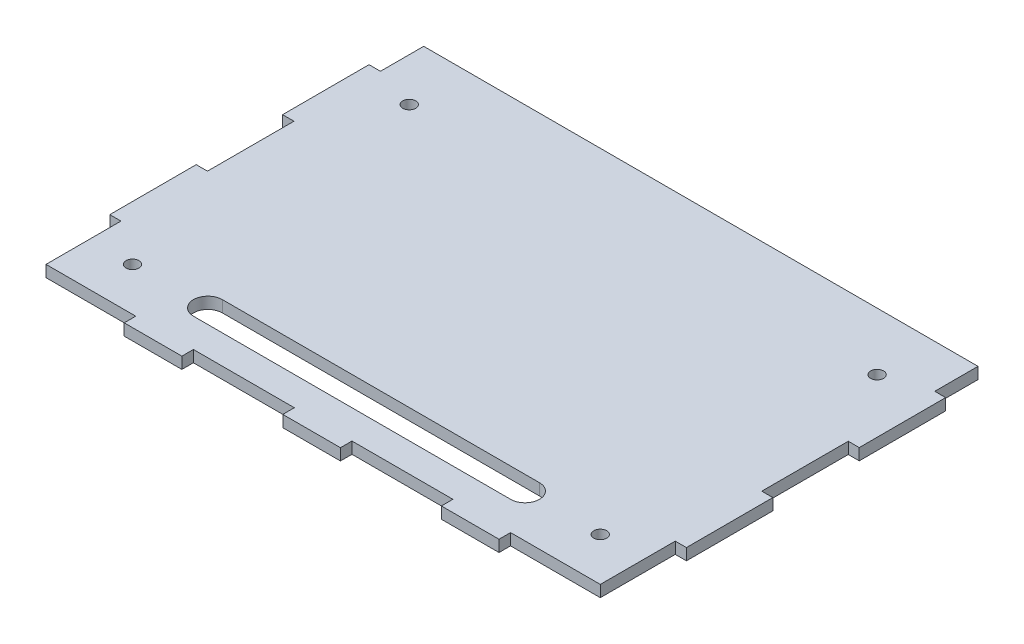
from build123d import *

# Parameters (mm, degrees)
RESSALTO_EXTRUS_O1_DEPTH = 4
ESBO_O2_W                = 35
ESBO_O2_H                = 4
ESBO_O2_W_2              = 3.874378487
ESBO_O2_H_2              = 26.000016438
CORTE_EXTRUS_O1_DEPTH    = 5
CORTE_EXTRUS_O5_REACH    = 6
ESBO_O6_W                = 32.376232368
ESBO_O6_H                = 43.313616366
ESBO_O3_W                = 192.251243026
ESBO_O3_H                = 15
CORTE_EXTRUS_O3_DEPTH    = 5
FURO_COM_FOLGA_DE_M41_D  = 4.5
ESBO_O5_R                = 2.25
CORTE_EXTRUS_O4_DEPTH    = 5


with BuildPart() as part:
    # Esboço1 → Ressalto-extrusão1 (new body)
    with BuildSketch(Plane(origin=(0, 0, 0), x_dir=(1, 0, 0), z_dir=(0, 1, 0))):
        Polygon((-100.157081707, 150), (-100.000054794, 0), (100.000054794, 0), (99.843027881, 150), align=None)
    extrude(amount=RESSALTO_EXTRUS_O1_DEPTH)

    # Esboço2 → Corte-extrusão1 (cut, through all)
    with BuildSketch(Plane(origin=(0, 4, 0), x_dir=(1, 0, 0), z_dir=(0, 1, 0))):
        Polygon((-100.125676325, 120), (-96.157081707, 120), (-96.157081707, 150), (-100.157081707, 150), align=None)
        Polygon((-100.062865577, 60.000016438), (-96.157081707, 60.000016438), (-96.157081707, 90), (-100.094270942, 90), align=None)
        Polygon((-100.004242179, 4), (-96.157081707, 4), (-96.157081707, 30.000016438), (-100.031460194, 30.000016438), align=None)
        Polygon((-100.000054794, 0), (-65.031460194, 0), (-65.031460194, 4), (-96.157081707, 4), (-100.004242179, 4), align=None)
        with Locations((-27.531460194, 2)):
            Rectangle(ESBO_O2_W, ESBO_O2_H)
        with Locations((27.468539806, 2)):
            Rectangle(ESBO_O2_W, ESBO_O2_H)
        Polygon((64.968539806, 4), (64.968539806, 0), (99.968539806, 0), (99.968539806, 4), (96.094161319, 4), align=None)
        with Locations((98.031350563, 17.000008219)):
            Rectangle(ESBO_O2_W_2, ESBO_O2_H_2)
        Polygon((96.094161319, 60.000016438), (99.937244012, 60.000016438), (99.905838646, 90), (96.094161319, 90), align=None)
        Polygon((99.843027881, 150), (96.094161319, 150), (96.094161319, 120), (99.874433264, 120), align=None)
    extrude(amount=-CORTE_EXTRUS_O1_DEPTH, mode=Mode.SUBTRACT)

    # Esboço6 → Corte-extrusão5 (cut, up to next)
    with BuildSketch(Plane(origin=(0, 4, 0), x_dir=(1, 0, 0), z_dir=(0, 1, 0)), mode=Mode.PRIVATE) as corte_extrus_o5_sk1:
        with Locations((112.282277503, 8.343208255)):
            Rectangle(ESBO_O6_W, ESBO_O6_H)
    corte_extrus_o5_tool1 = extrude(corte_extrus_o5_sk1.sketch, amount=-CORTE_EXTRUS_O5_REACH, mode=Mode.PRIVATE) & part.part
    add(corte_extrus_o5_tool1.solids().sort_by_distance((112.282278, 4, -8.343208))[0], mode=Mode.SUBTRACT)

    # Esboço3 → Corte-extrusão3 (cut, through all)
    with BuildSketch(Plane(origin=(0, 4, 0), x_dir=(1, 0, 0), z_dir=(0, 1, 0))):
        with Locations((-0.031460194, 142.5)):
            Rectangle(ESBO_O3_W, ESBO_O3_H)
    extrude(amount=-CORTE_EXTRUS_O3_DEPTH, mode=Mode.SUBTRACT)

    # Furo com folga de M41 (through all)
    with Locations(Plane(origin=(-81.157081707, 4, -19), x_dir=(0, 0, 1), z_dir=(0, 1, 0))):
        with Locations((0, 0), (-96, 0), (-96, 162.251243026), (0, 162.251243026)):
            Hole(FURO_COM_FOLGA_DE_M41_D / 2)

    # Esboço5 → Corte-extrusão4 (cut, through all)
    with BuildSketch(Plane(origin=(0, 4, 0), x_dir=(1, 0, 0), z_dir=(0, 1, 0))):
        with Locations((-81.157081707, 19)):
            Circle(ESBO_O5_R)
        with BuildLine():
            Line((-55, 24), (55, 24))
            ThreePointArc((55, 24), (60, 19), (55, 14))
            Line((55, 14), (-55, 14))
            ThreePointArc((-55, 14), (-60, 19), (-55, 24))
        make_face()
    extrude(amount=-CORTE_EXTRUS_O4_DEPTH, mode=Mode.SUBTRACT)


solid = part.part
